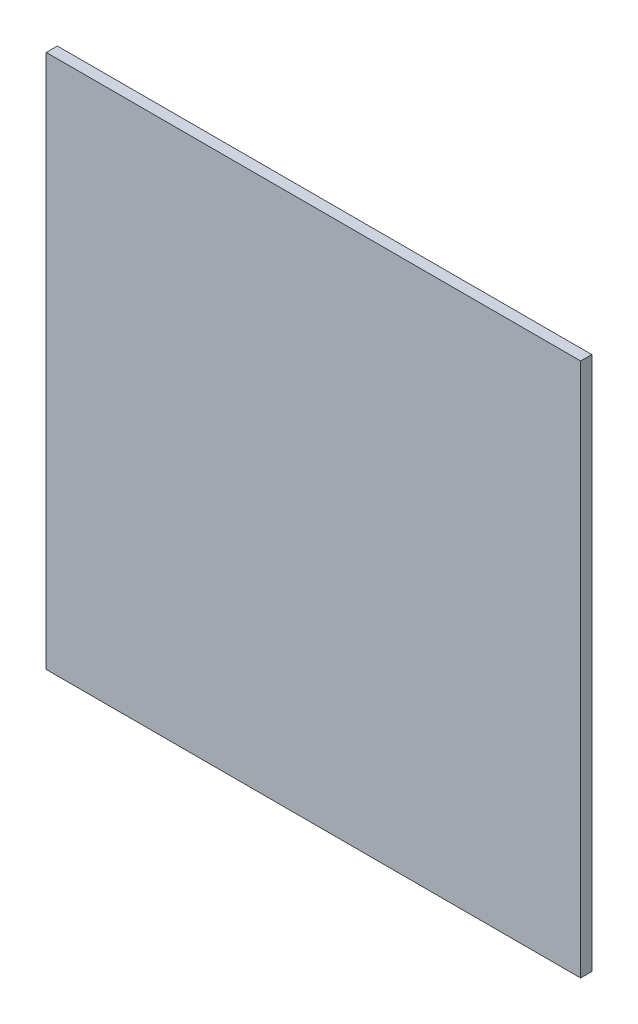
from build123d import *

# Parameters (mm, degrees)
SKETCH1_W           = 609.6
SKETCH1_H           = 609.6
BOSS_EXTRUDE1_DEPTH = 12.7


with BuildPart() as part:
    # Sketch1 → Boss-Extrude1 (new body)
    with BuildSketch(Plane.XY):
        with Locations((304.8, 304.8)):
            Rectangle(SKETCH1_W, SKETCH1_H)
    extrude(amount=BOSS_EXTRUDE1_DEPTH)


solid = part.part
